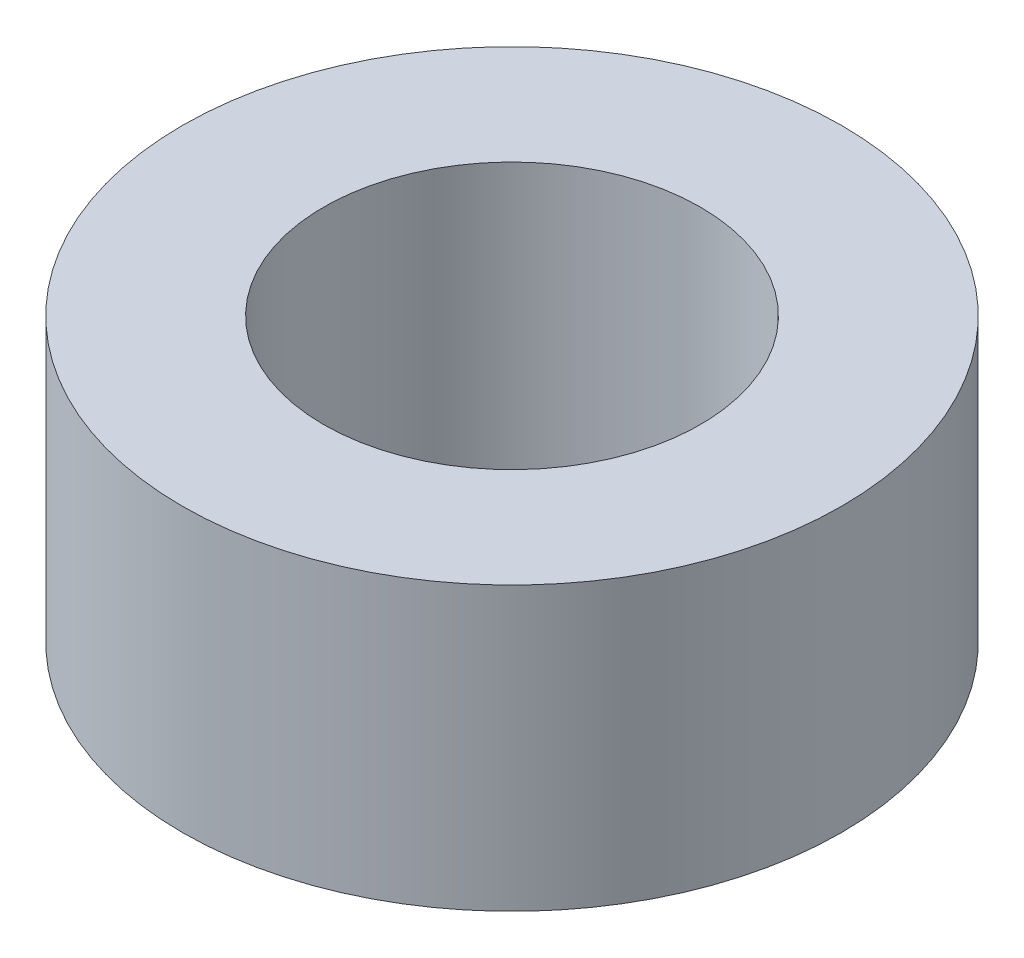
from build123d import *

# Parameters (mm, degrees)
SKETCH1_R           = 3.5
SKETCH1_R_2         = 2
BOSS_EXTRUDE1_DEPTH = 3


with BuildPart() as part:
    # Sketch1 → Boss-Extrude1 (new body)
    with BuildSketch(Plane(origin=(0, 0, 0), x_dir=(1, 0, 0), z_dir=(0, 1, 0))):
        Circle(SKETCH1_R)
        Circle(SKETCH1_R_2, mode=Mode.SUBTRACT)
    extrude(amount=BOSS_EXTRUDE1_DEPTH)


solid = part.part
